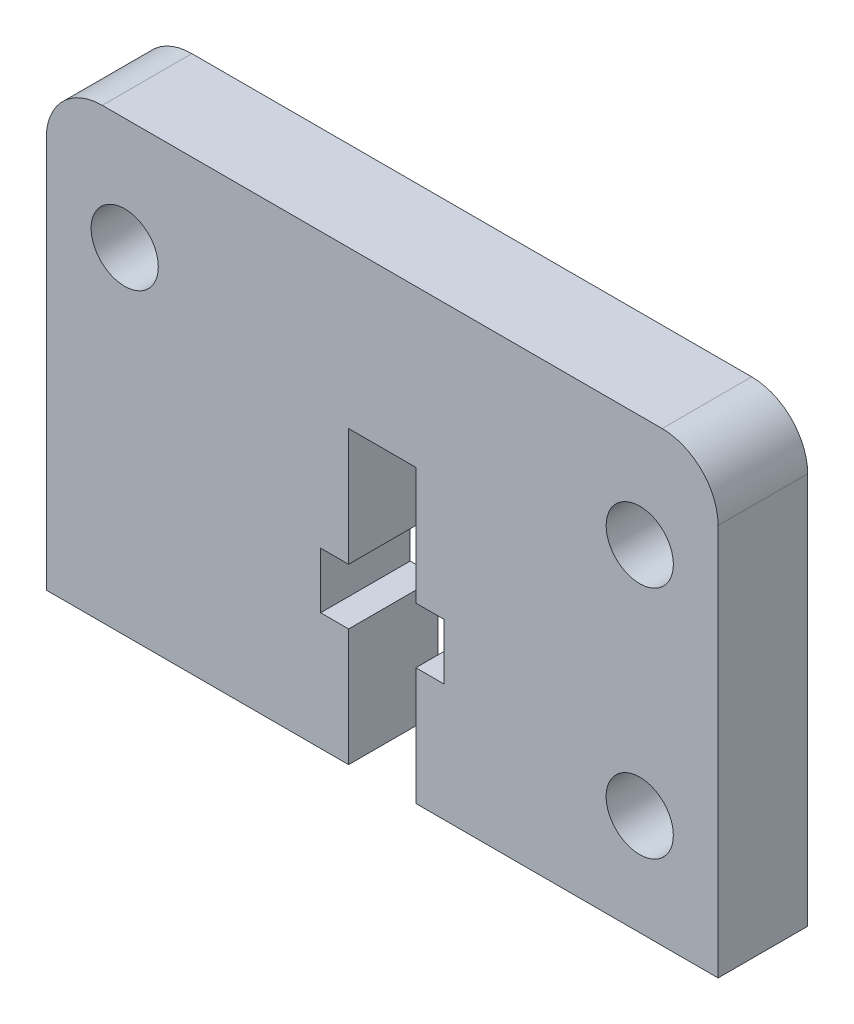
from build123d import *

# Parameters (mm, degrees)
SKETCH_1_R               = 1.5
EXTRUDE_1_DEPTH          = 4
CUT_EXTRUDE_1_DEPTH      = 1
CUT_EXTRUDE_1_DEPTH_BACK = 4


with BuildPart() as part:
    # Эскиз1 → Бобышка-Вытянуть1 (new body)
    with BuildSketch(Plane.XY):
        with BuildLine():
            Line((0, 0), (30, 0))
            Line((30, 0), (30, 17.5))
            ThreePointArc((30, 17.5), (29.267766953, 19.267766953), (27.5, 20))
            Line((27.5, 20), (2.5, 20))
            ThreePointArc((2.5, 20), (0.732233047, 19.267766953), (0, 17.5))
            Line((0, 17.5), (0, 0))
        make_face()
        with Locations((3.5, 15)):
            Circle(SKETCH_1_R, mode=Mode.SUBTRACT)
        with Locations((26.5, 15)):
            Circle(SKETCH_1_R, mode=Mode.SUBTRACT)
        with Locations((26.5, 4.52)):
            Circle(SKETCH_1_R, mode=Mode.SUBTRACT)
    extrude(amount=EXTRUDE_1_DEPTH)

    # Эскиз2 → Вырез-Вытянуть1 (cut, two sides)
    with BuildSketch(Plane.XY.offset(4)) as cut_extrude_1_sk:
        Polygon((13.5, 5.25), (13.5, 0), (16.5, 0), (16.5, 5.25), (17.75, 5.25), (17.75, 7.75), (16.5, 7.75), (16.5, 13), (13.5, 13), (13.5, 7.75), (12.25, 7.75), (12.25, 5.25), align=None)
    extrude(amount=CUT_EXTRUDE_1_DEPTH, mode=Mode.SUBTRACT)
    extrude(cut_extrude_1_sk.sketch, amount=-CUT_EXTRUDE_1_DEPTH_BACK, mode=Mode.SUBTRACT)


solid = part.part
